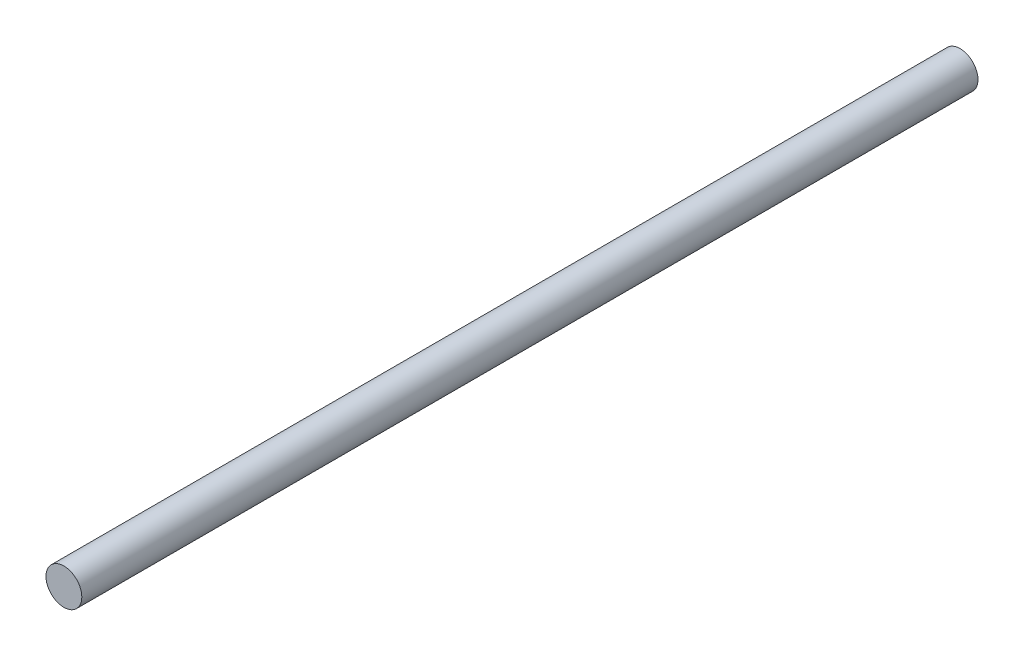
from build123d import *

# Parameters (mm, degrees)
SKETCH_1_R      = 4
EXTRUDE_1_DEPTH = 200


with BuildPart() as part:
    # Эскиз1 → Бобышка-Вытянуть1 (new body)
    with BuildSketch(Plane.XY):
        Circle(SKETCH_1_R)
    extrude(amount=EXTRUDE_1_DEPTH)


solid = part.part
